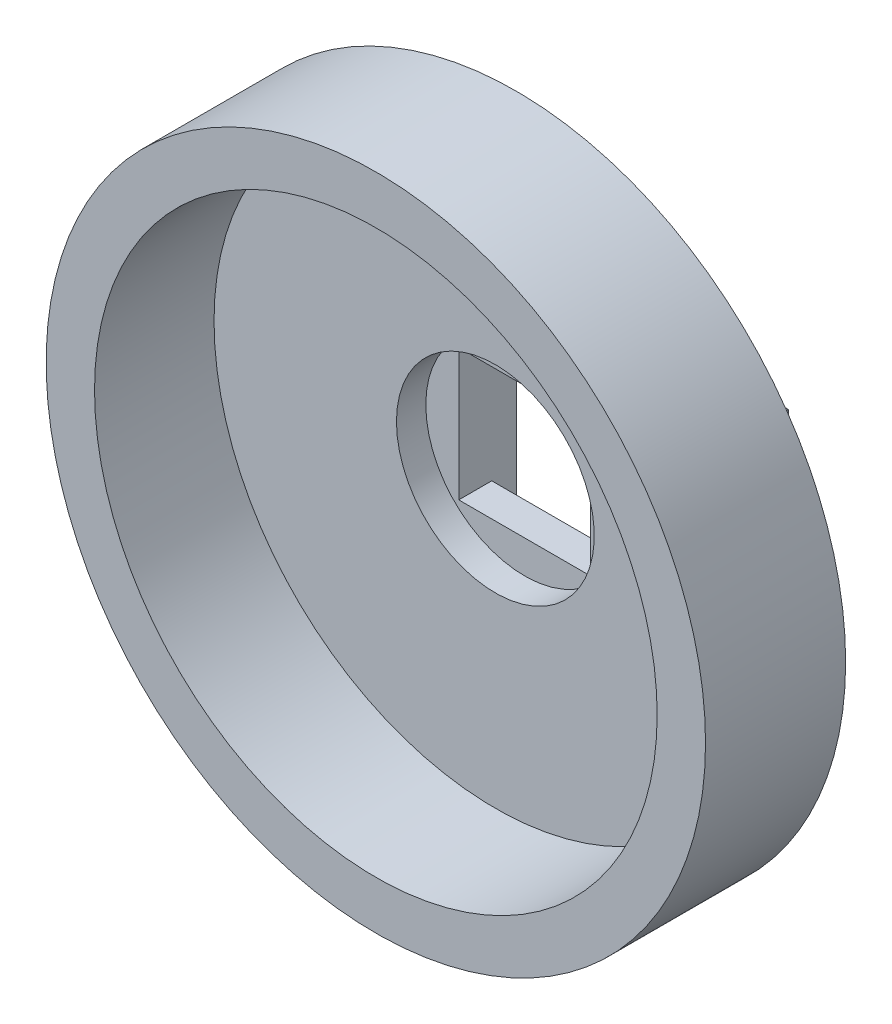
from build123d import *

# Parameters (mm, degrees)
SKETCH1_W                    = 25
SKETCH1_H                    = 15
BOSS_EXTRUDE1_DEPTH          = 4.03
M2_TAPPED_HOLE1_D            = 1.6
M2_TAPPED_HOLE1_DEPTH        = 3
M2_TAPPED_HOLE1_TIP          = 0.480688495
SKETCH5_R                    = 20
BOSS_EXTRUDE2_DEPTH          = 8.5
SKETCH6_R                    = 12.25
CUT_EXTRUDE1_DEPTH           = 5.25
F_1_1_2_6_TAPPED_HOLE1_D     = 34.13252
F_1_1_2_6_TAPPED_HOLE1_DEPTH = 7.25
CUT_EXTRUDE2_DEPTH           = 3.5
SKETCH14_W                   = 8
SKETCH14_H                   = 1.5
CUT_EXTRUDE3_DEPTH           = 13.5
SKETCH15_R                   = 6
CUT_EXTRUDE4_DEPTH           = 13.5


with BuildPart() as part:
    # Sketch1 → Boss-Extrude1 (new body)
    with BuildSketch(Plane.XY):
        with Locations((12.5, 7.5)):
            Rectangle(SKETCH1_W, SKETCH1_H)
    extrude(amount=BOSS_EXTRUDE1_DEPTH)

    # M2 Tapped Hole1
    with Locations(Plane(origin=(0, 0, 0), x_dir=(-1, 0, 0), z_dir=(0, 0, -1))):
        with Locations((-23, 7.5), (-2, 7.5)):
            Hole(M2_TAPPED_HOLE1_D / 2, depth=M2_TAPPED_HOLE1_DEPTH)
            with Locations((0, 0, -(M2_TAPPED_HOLE1_DEPTH + M2_TAPPED_HOLE1_TIP / 2))):  # 118° drill point
                Cone(0, M2_TAPPED_HOLE1_D / 2, M2_TAPPED_HOLE1_TIP, mode=Mode.SUBTRACT)

    # Sketch5 → Boss-Extrude2 (add)
    with BuildSketch(Plane.XY.offset(4.03)):
        with Locations((12.5, 7.5)):
            Circle(SKETCH5_R)
    extrude(amount=BOSS_EXTRUDE2_DEPTH)

    # Sketch6 → Cut-Extrude1 (cut)
    with BuildSketch(Plane.XY.offset(12.53)):
        with Locations((12.5, 7.5)):
            Circle(SKETCH6_R)
    extrude(amount=-CUT_EXTRUDE1_DEPTH, mode=Mode.SUBTRACT)

    # 1-1/2-6 Tapped Hole1
    with Locations(Plane.XY.offset(12.53)):
        with Locations((12.5, 7.5)):
            Hole(F_1_1_2_6_TAPPED_HOLE1_D / 2, depth=F_1_1_2_6_TAPPED_HOLE1_DEPTH)

    # Sketch13 → Cut-Extrude2 (cut)
    with BuildSketch(Plane(origin=(0, 0, 0), x_dir=(-1, 0, 0), z_dir=(0, 0, -1))):
        Polygon((-12.5, 3.75), (-12.5, 7.5), (-12.5, 7.75), (-12.5, 11.75), (-16.5, 11.75), (-16.5, 3.75), align=None)
        Polygon((-12.5, 7.75), (-12.5, 7.5), (-12.5, 3.75), (-8.5, 3.75), (-8.5, 11.75), (-12.5, 11.75), align=None)
    extrude(amount=-CUT_EXTRUDE2_DEPTH, mode=Mode.SUBTRACT)

    # Sketch14 → Cut-Extrude3 (cut)
    with BuildSketch(Plane(origin=(0, 3.75, 0), x_dir=(1, 0, 0), z_dir=(0, 1, 0))):
        with Locations((12.5, -0.75)):
            Rectangle(SKETCH14_W, SKETCH14_H)
    extrude(amount=-CUT_EXTRUDE3_DEPTH, mode=Mode.SUBTRACT)

    # Sketch15 → Cut-Extrude4 (cut)
    with BuildSketch(Plane(origin=(0, 0, 3.5), x_dir=(-1, 0, 0), z_dir=(0, 0, -1))):
        with Locations((-12.5, 7.75)):
            Circle(SKETCH15_R)
    extrude(amount=-CUT_EXTRUDE4_DEPTH, mode=Mode.SUBTRACT)


solid = part.part
